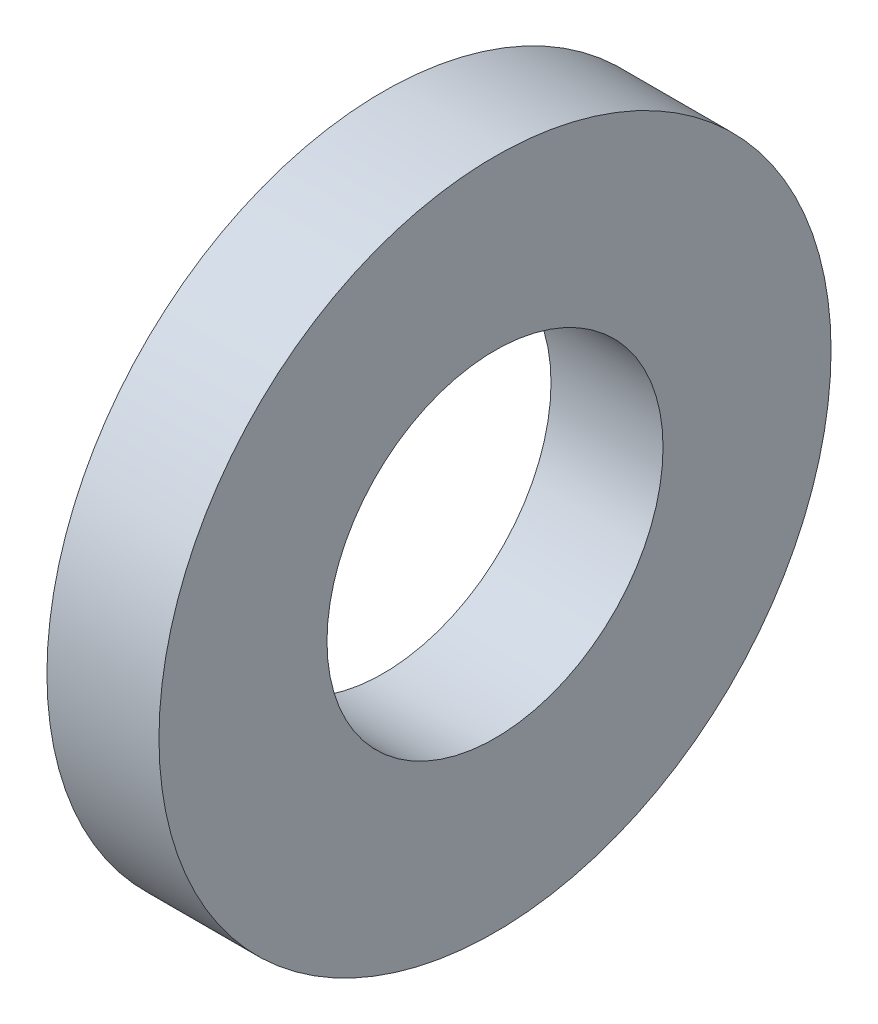
from build123d import *

# Parameters (mm, degrees)
SKETCH1_W = 1
SKETCH1_H = 1.5


with BuildPart() as part:
    # Sketch1 → Revolve1 (revolve)
    with BuildSketch(Plane.XY):
        with Locations((0.5, 2.25)):
            Rectangle(SKETCH1_W, SKETCH1_H)
    revolve(axis=Axis((0, 0, 0), (1, 0, 0)))


solid = part.part
